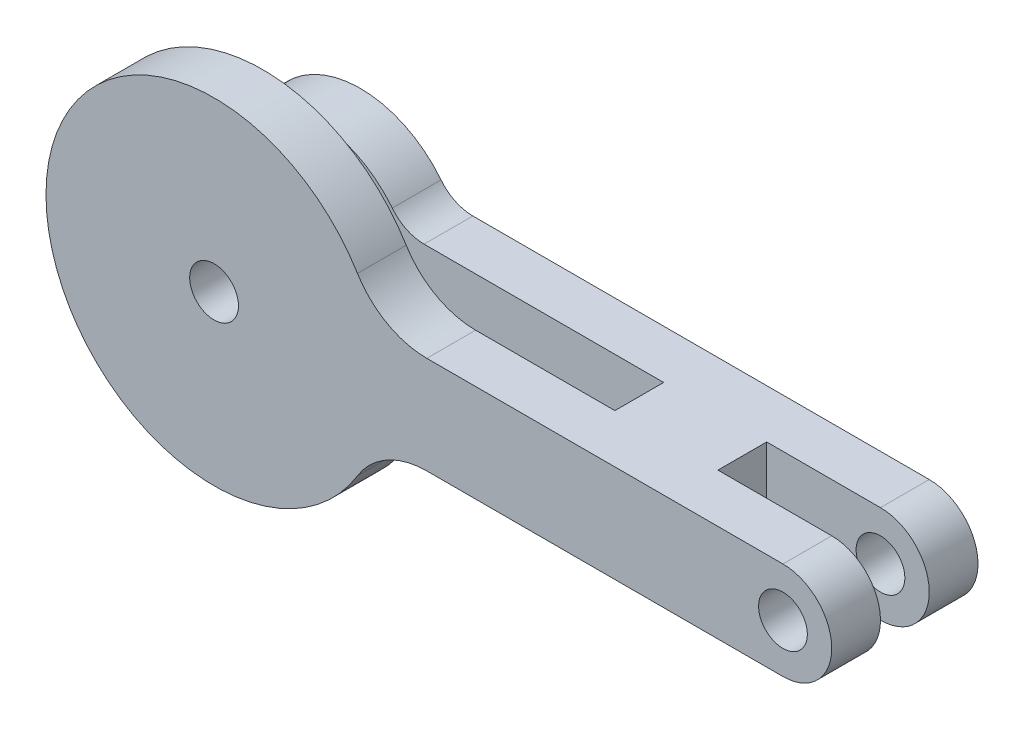
from build123d import *

# Parameters (mm, degrees)
ESTRUSIONE_ESTRUSIONE1_DEPTH      = 4.5
ESTRUSIONE_ESTRUSIONE1_DEPTH_BACK = 4.5
SCHIZZO1_R                        = 1.5
TAGLIO_ESTRUSIONE1_DEPTH          = 12.277661417
TAGLIO_ESTRUSIONE1_DEPTH_BACK     = 23.284267349
SCHIZZO2_W                        = 32
SCHIZZO2_H                        = 3
SCHIZZO2_W_2                      = 10
TAGLIO_ESTRUSIONE3_DEPTH          = 3.5
RACCORDO1_R                       = 5
RACCORDO2_R                       = 5
RACCORDO3_R                       = 2.5
RACCORDO4_R                       = 2.5


with BuildPart() as part:
    # Schizzo1 → Estrusione-Estrusione1 (new, two sides: drawn at the far end of the back side and taken through both)
    with BuildSketch(Plane.XY.offset(-ESTRUSIONE_ESTRUSIONE1_DEPTH_BACK)):
        with BuildLine():
            ThreePointArc((9.895231175, 3), (-10.34, 0), (9.895231175, -3))
            Line((9.895231175, -3), (35, -3))
            ThreePointArc((35, -3), (38, 0), (35, 3))
            Line((35, 3), (9.895231175, 3))
        make_face()
        Circle(SCHIZZO1_R, mode=Mode.SUBTRACT)
        with Locations((35, 0)):
            Circle(SCHIZZO1_R, mode=Mode.SUBTRACT)
    extrude(amount=ESTRUSIONE_ESTRUSIONE1_DEPTH + ESTRUSIONE_ESTRUSIONE1_DEPTH_BACK)

    # Schizzo2 → Taglio-Estrusione1 (cut, two sides: drawn at the far end of the back side and taken through both)
    with BuildSketch(Plane(origin=(0, -3, 0), x_dir=(-1, 0, 0), z_dir=(0, -1, 0)).offset(-TAGLIO_ESTRUSIONE1_DEPTH_BACK)):
        with Locations((-5.66, 0)):
            Rectangle(SCHIZZO2_W, SCHIZZO2_H)
        with Locations((-33, 0)):
            Rectangle(SCHIZZO2_W_2, SCHIZZO2_H)
    extrude(amount=TAGLIO_ESTRUSIONE1_DEPTH + TAGLIO_ESTRUSIONE1_DEPTH_BACK, mode=Mode.SUBTRACT)

    # Schizzo18 → Taglio-Estrusione3 (cut)
    with BuildSketch(Plane(origin=(0, 0, -4.5), x_dir=(-1, 0, 0), z_dir=(0, 0, -1))):
        with BuildLine():
            Line((-9.895231175, 3), (-5.58530214, 3))
            ThreePointArc((-5.58530214, 3), (6.34, 0), (-5.58530214, -3))
            Line((-5.58530214, -3), (-9.895231175, -3))
            ThreePointArc((-9.895231175, -3), (10.34, 0), (-9.895231175, 3))
        make_face()
    extrude(amount=-TAGLIO_ESTRUSIONE3_DEPTH, mode=Mode.SUBTRACT)

    # Raccordo1
    raccordo1_edges = [part.edges().sort_by_distance(p)[0] for p in [
        (9.895231175, 3, 3),
    ]]
    fillet(raccordo1_edges, radius=RACCORDO1_R)

    # Raccordo2
    raccordo2_edges = [part.edges().sort_by_distance(p)[0] for p in [
        (9.895231175, -3, 3),
    ]]
    fillet(raccordo2_edges, radius=RACCORDO2_R)

    # Raccordo3
    raccordo3_edges = [part.edges().sort_by_distance(p)[0] for p in [
        (5.58530214, 3, -3),
    ]]
    fillet(raccordo3_edges, radius=RACCORDO3_R)

    # Raccordo4
    raccordo4_edges = [part.edges().sort_by_distance(p)[0] for p in [
        (5.58530214, -3, -3),
    ]]
    fillet(raccordo4_edges, radius=RACCORDO4_R)


solid = part.part
